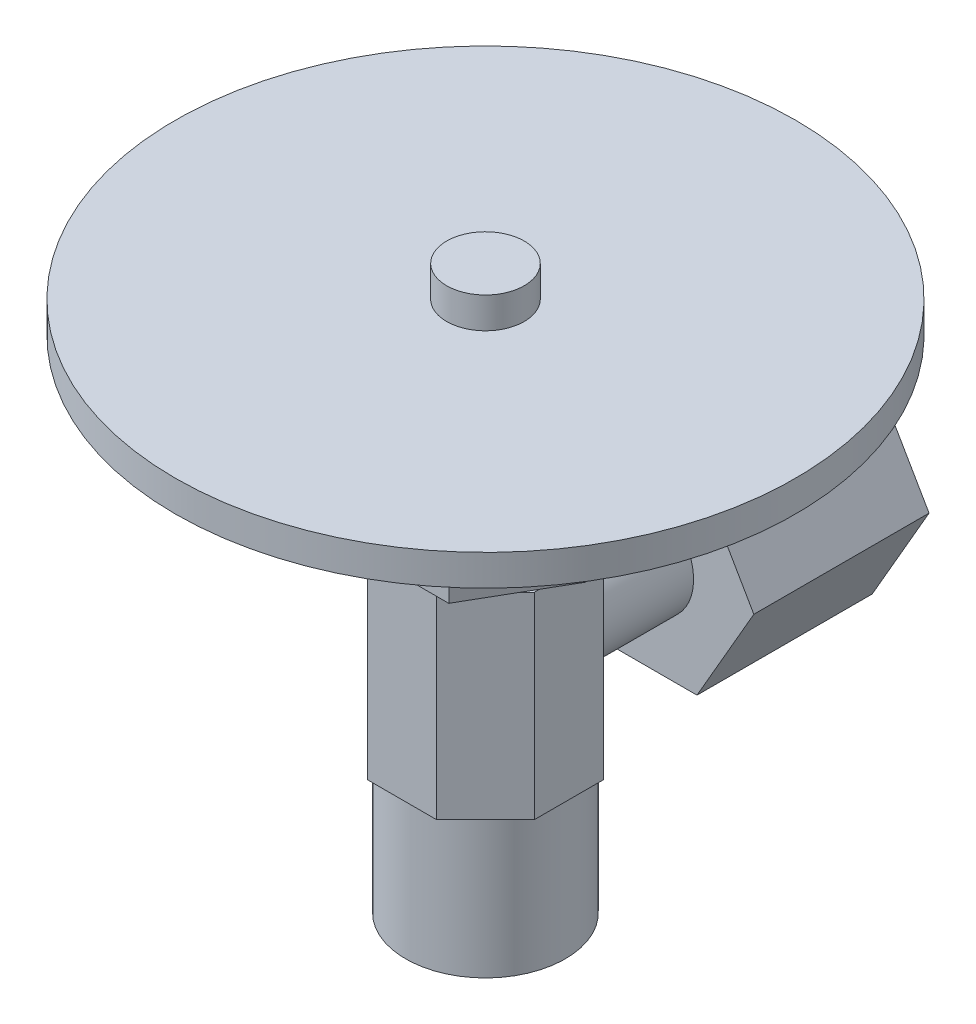
from build123d import *

# Parameters (mm, degrees)
BOSS_EXTRUDE1_DEPTH      = 12.7
SKETCH2_R                = 3.445005279
BOSS_EXTRUDE2_DEPTH      = 4.6
BOSS_EXTRUDE2_DEPTH_BACK = 2
BOSS_EXTRUDE3_DEPTH      = 11.3
SKETCH4_R                = 5.15
BOSS_EXTRUDE4_DEPTH      = 9
BOSS_EXTRUDE5_DEPTH      = 8.57
SKETCH6_R                = 2.5
BOSS_EXTRUDE6_DEPTH      = 6
BOSS_EXTRUDE7_START      = -2
SKETCH7_R                = 20
BOSS_EXTRUDE7_DEPTH      = 2


with BuildPart() as part:
    # Sketch1 → Boss-Extrude1 (new body)
    with BuildSketch(Plane(origin=(0, 0, 0), x_dir=(1, 0, 0), z_dir=(0, 1, 0))):
        Polygon((-2.226397898, -5.375), (2.226397898, -5.375), (5.375, -2.226397898), (5.375, 2.226397898), (2.226397898, 5.375), (-2.226397898, 5.375), (-5.375, 2.226397898), (-5.375, -2.226397898), align=None)
    extrude(amount=BOSS_EXTRUDE1_DEPTH)

    # Sketch2 → Boss-Extrude2 (add, two sides)
    with BuildSketch(Plane(origin=(0, 0, -5.375), x_dir=(-1, 0, 0), z_dir=(0, 0, -1))) as boss_extrude2_sk:
        with Locations((0, 6.35)):
            Circle(SKETCH2_R)
    extrude(amount=BOSS_EXTRUDE2_DEPTH)
    extrude(boss_extrude2_sk.sketch, amount=-BOSS_EXTRUDE2_DEPTH_BACK)

    # Sketch3 → Boss-Extrude3 (add)
    with BuildSketch(Plane(origin=(0, 0, -9.975), x_dir=(-1, 0, 0), z_dir=(0, 0, -1))):
        Polygon((7.332348419, 6.35), (3.666174209, 12.7), (-3.666174209, 12.7), (-7.332348419, 6.35), (-3.666174209, 0), (3.666174209, 0), align=None)
    extrude(amount=BOSS_EXTRUDE3_DEPTH)

    # Sketch4 → Boss-Extrude4 (add)
    with BuildSketch(Plane.XZ):
        Circle(SKETCH4_R)
    extrude(amount=BOSS_EXTRUDE4_DEPTH)

    # Sketch5 → Boss-Extrude5 (add)
    with BuildSketch(Plane(origin=(0, 12.7, 0), x_dir=(1, 0, 0), z_dir=(0, 1, 0))):
        Polygon((6.466323015, 0), (3.233161507, 5.6), (-3.233161507, 5.6), (-6.466323015, 0), (-3.233161507, -5.6), (3.233161507, -5.6), align=None)
    extrude(amount=BOSS_EXTRUDE5_DEPTH)

    # Sketch6 → Boss-Extrude6 (add)
    with BuildSketch(Plane(origin=(0, 21.27, 0), x_dir=(1, 0, 0), z_dir=(0, 1, 0))):
        Circle(SKETCH6_R)
    extrude(amount=BOSS_EXTRUDE6_DEPTH)

    # Sketch7 → Boss-Extrude7 (add)
    with BuildSketch(Plane(origin=(0, 27.27, 0), x_dir=(1, 0, 0), z_dir=(0, 1, 0)).offset(BOSS_EXTRUDE7_START)):
        Circle(SKETCH7_R)
    extrude(amount=-BOSS_EXTRUDE7_DEPTH)


solid = part.part
